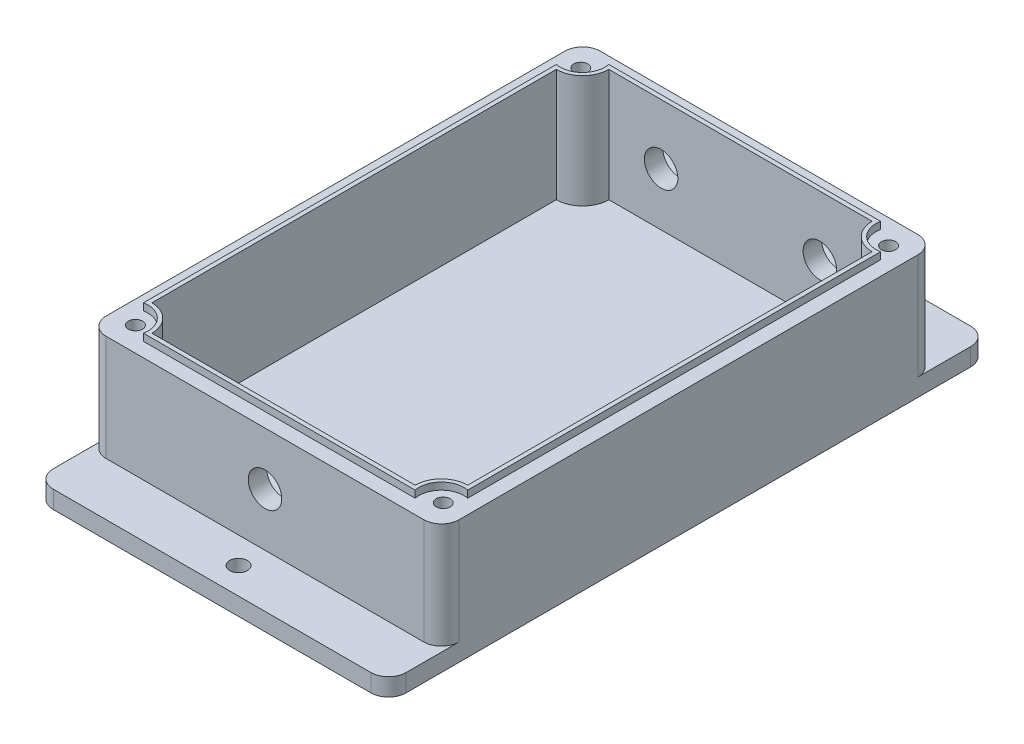
from build123d import *

# Parameters (mm, degrees)
BOTTOM_DEPTH       = 5
WALL_W             = 100
WALL_H             = 140
WALL_W_2           = 89.5
WALL_H_2           = 129.5
WALLS_DEPTH        = 30
MAINFILLET_R       = 5
DRILLHOLES_R       = 2
DRILLING_DEPTH     = 45
GASKET_DEPTH       = 2
SKETCH1_R          = 4.75
CUT_EXTRUDE1_DEPTH = 10
IO_HOLES_R         = 4.75
CUT_EXTRUDE2_DEPTH = 70
SKETCH2_R          = 2.5
CUT_EXTRUDE3_DEPTH = 10


with BuildPart() as part:
    # Base → Bottom (new body)
    with BuildSketch(Plane(origin=(0, 0, 0), x_dir=(1, 0, 0), z_dir=(0, 1, 0))):
        Polygon((-50, -70), (-50, 70), (-50, 85), (50, 85), (50, 70), (50, -70), (50, -85), (-50, -85), align=None)
    extrude(amount=-BOTTOM_DEPTH)

    # Wall → Walls (add)
    with BuildSketch(Plane(origin=(0, 0, 0), x_dir=(1, 0, 0), z_dir=(0, 1, 0))):
        Rectangle(WALL_W, WALL_H)
        Rectangle(WALL_W_2, WALL_H_2, mode=Mode.SUBTRACT)
        with BuildLine():
            Line((-44.75, -57.3), (-44.75, -64.75))
            Line((-44.75, -64.75), (-37.3, -64.75))
            ThreePointArc((-37.3, -64.75), (-39.48205448, -59.48205448), (-44.75, -57.3))
        make_face()
        with BuildLine():
            ThreePointArc((44.75, -57.3), (39.48205448, -59.48205448), (37.3, -64.75))
            Line((37.3, -64.75), (44.75, -64.75))
            Line((44.75, -64.75), (44.75, -57.3))
        make_face()
        with BuildLine():
            Line((-44.75, 64.75), (-44.75, 57.3))
            ThreePointArc((-44.75, 57.3), (-39.48205448, 59.48205448), (-37.3, 64.75))
            Line((-37.3, 64.75), (-44.75, 64.75))
        make_face()
        with BuildLine():
            Line((44.75, 64.75), (37.3, 64.75))
            ThreePointArc((37.3, 64.75), (39.48205448, 59.48205448), (44.75, 57.3))
            Line((44.75, 57.3), (44.75, 64.75))
        make_face()
    extrude(amount=WALLS_DEPTH)

    # MainFillet
    mainfillet_edges = [part.edges().sort_by_distance(p)[0] for p in [
        (-50, -2.5, 85),
        (-50, -2.5, -85),
        (50, -2.5, -85),
        (50, -2.5, 85),
        (-50, 15, 70),
        (50, 15, 70),
        (50, 15, -70),
        (-50, 15, -70),
    ]]
    fillet(mainfillet_edges, radius=MAINFILLET_R)

    # DrillHoles → Drilling (cut)
    with BuildSketch(Plane(origin=(0, 30, 0), x_dir=(-1, 0, 0), z_dir=(0, -1, 0))):
        with Locations((43.612901731, 63.104701387)):
            Circle(DRILLHOLES_R)
        with Locations((43.612901731, -63.104701387)):
            Circle(DRILLHOLES_R)
        with Locations((-43.612901731, -63.104701387)):
            Circle(DRILLHOLES_R)
        with Locations((-43.612901731, 63.104701387)):
            Circle(DRILLHOLES_R)
    extrude(amount=DRILLING_DEPTH, mode=Mode.SUBTRACT)

    # GasketInsert → Gasket (add)
    with BuildSketch(Plane(origin=(0, 30, 0), x_dir=(1, 0, 0), z_dir=(0, 1, 0))):
        with BuildLine():
            Line((-45.95, -58.5), (-45.95, 58.5))
            ThreePointArc((-45.95, 58.5), (-40.249861113, 60.249861113), (-38.5, 65.95))
            Line((-38.5, 65.95), (38.5, 65.95))
            ThreePointArc((38.5, 65.95), (40.249861113, 60.249861113), (45.95, 58.5))
            Line((45.95, 58.5), (45.95, -58.5))
            ThreePointArc((45.95, -58.5), (40.249861113, -60.249861113), (38.5, -65.95))
            Line((38.5, -65.95), (-38.5, -65.95))
            ThreePointArc((-38.5, -65.95), (-40.249861113, -60.249861113), (-45.95, -58.5))
        make_face()
        with BuildLine():
            Line((-37.3, -64.75), (37.3, -64.75))
            ThreePointArc((37.3, -64.75), (39.48205448, -59.48205448), (44.75, -57.3))
            Line((44.75, -57.3), (44.75, 57.3))
            ThreePointArc((44.75, 57.3), (39.48205448, 59.48205448), (37.3, 64.75))
            Line((37.3, 64.75), (-37.3, 64.75))
            ThreePointArc((-37.3, 64.75), (-39.48205448, 59.48205448), (-44.75, 57.3))
            Line((-44.75, 57.3), (-44.75, -57.3))
            ThreePointArc((-44.75, -57.3), (-39.48205448, -59.48205448), (-37.3, -64.75))
        make_face(mode=Mode.SUBTRACT)
    extrude(amount=GASKET_DEPTH)

    # Sketch1 → Cut-Extrude1 (cut)
    with BuildSketch(Plane.XY.offset(70)):
        with Locations((0, 15)):
            Circle(SKETCH1_R)
    extrude(amount=-CUT_EXTRUDE1_DEPTH, mode=Mode.SUBTRACT)

    # IO Holes → Cut-Extrude2 (cut)
    with BuildSketch(Plane.XY):
        with Locations((-22.5, 15)):
            Circle(IO_HOLES_R)
        with Locations((22.5, 15)):
            Circle(IO_HOLES_R)
    extrude(amount=-CUT_EXTRUDE2_DEPTH, mode=Mode.SUBTRACT)

    # Sketch2 → Cut-Extrude3 (cut)
    with BuildSketch(Plane(origin=(0, 0, 0), x_dir=(1, 0, 0), z_dir=(0, 1, 0))):
        with Locations((0, 77.5)):
            Circle(SKETCH2_R)
        with Locations((0, -77.5)):
            Circle(SKETCH2_R)
    extrude(amount=-CUT_EXTRUDE3_DEPTH, mode=Mode.SUBTRACT)


solid = part.part
